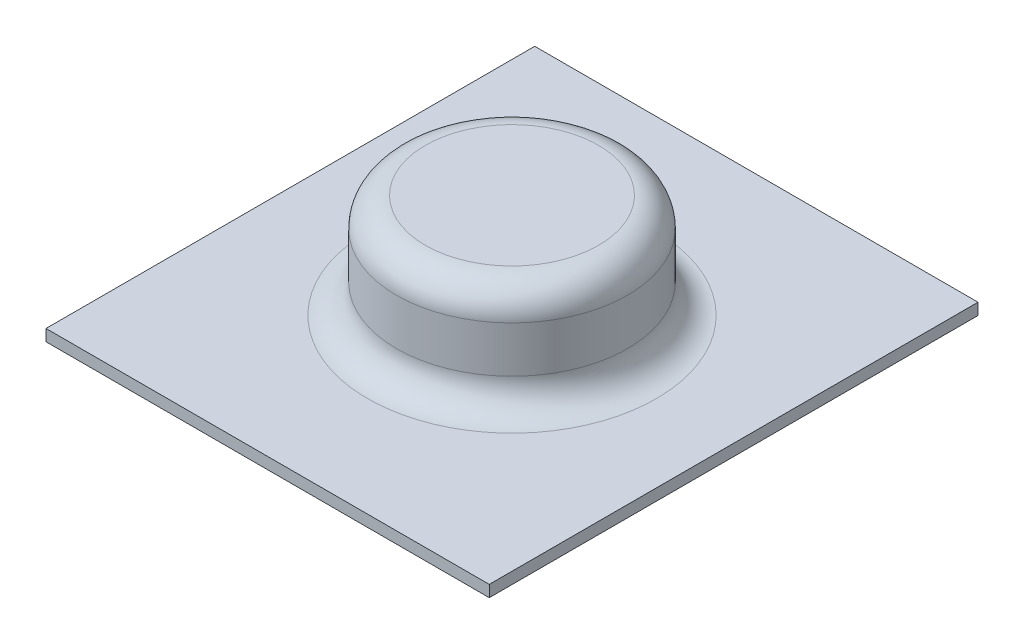
from build123d import *

# Parameters (mm, degrees)
SKETCH1_W           = 19.5
SKETCH1_H           = 21.5
BOSS_EXTRUDE1_DEPTH = 0.508
SKETCH2_R           = 5.08
BOSS_EXTRUDE2_DEPTH = 5.08
FILLET1_R           = 1.27


with BuildPart() as part:
    # Sketch1 → Boss-Extrude1 (new body)
    with BuildSketch(Plane(origin=(0, 0, 0), x_dir=(1, 0, 0), z_dir=(0, 1, 0))):
        Rectangle(SKETCH1_W, SKETCH1_H)
    extrude(amount=BOSS_EXTRUDE1_DEPTH)

    # Sketch2 → Boss-Extrude2 (add)
    with BuildSketch(Plane(origin=(0, 0, 0), x_dir=(1, 0, 0), z_dir=(0, 1, 0))):
        Circle(SKETCH2_R)
    extrude(amount=BOSS_EXTRUDE2_DEPTH)

    # Fillet1
    fillet1_edges = [part.edges().sort_by_distance(p)[0] for p in [
        (-5.08, 0.508, 0),
        (-5.08, 5.08, 0),
    ]]
    fillet(fillet1_edges, radius=FILLET1_R)


solid = part.part
